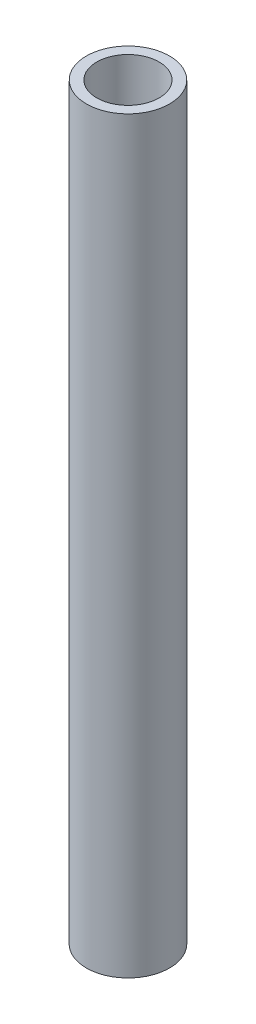
from build123d import *

# Parameters (mm, degrees)
SKETCH1_R           = 12.7
SKETCH1_R_2         = 9.525
BOSS_EXTRUDE2_DEPTH = 228.6


with BuildPart() as part:
    # Sketch1 → Boss-Extrude2 (new body)
    with BuildSketch(Plane(origin=(0, 0, 0), x_dir=(1, 0, 0), z_dir=(0, 1, 0))):
        with Locations((-391.181668083, 212.743279788)):
            Circle(SKETCH1_R)
        with Locations((-391.181668083, 212.743279788)):
            Circle(SKETCH1_R_2, mode=Mode.SUBTRACT)
    extrude(amount=BOSS_EXTRUDE2_DEPTH)


solid = part.part
